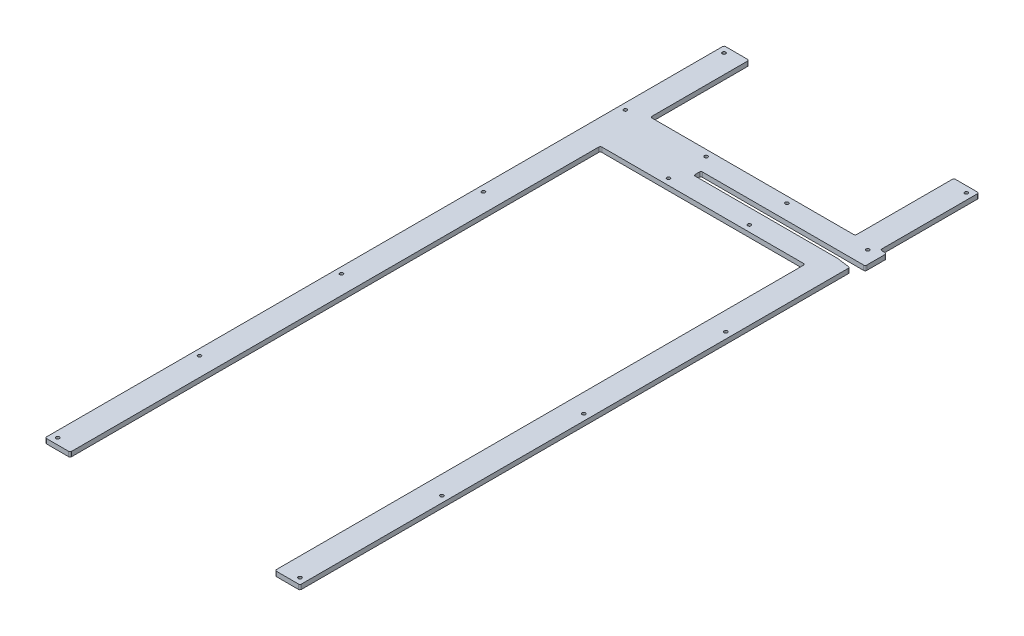
from build123d import *

# Parameters (mm, degrees)
BOSS_EXTRUDE1_DEPTH                                 = 9.525
SKETCH4_W                                           = 50.8
SKETCH4_H                                           = 200
BOSS_EXTRUDE2_DEPTH                                 = 9.525
CSK_FOR_1_4_FLAT_HEAD_MACHINE_SCREW_100_D           = 6.7564
CSK_FOR_1_4_FLAT_HEAD_MACHINE_SCREW_100_CSINK_D     = 17.6447958
CSK_FOR_1_4_FLAT_HEAD_MACHINE_SCREW_100_CSINK_ANGLE = 100
LPATTERN1_COUNT                                     = 2
LPATTERN1_PITCH                                     = 491.2
LPATTERN1_COUNT_DIR2                                = 5
LPATTERN1_PITCH_DIR2                                = 287.65
LPATTERN2_COUNT                                     = 3
LPATTERN2_PITCH                                     = 163.733333333
LPATTERN2_COUNT_DIR2                                = 2
LPATTERN2_PITCH_DIR2                                = 76.2
CSK_FOR_1_4_FLAT_HEAD_MACHINE_SCREW_2_D             = 6.7564
CSK_FOR_1_4_FLAT_HEAD_MACHINE_SCREW_2_CSINK_D       = 17.6447958
CSK_FOR_1_4_FLAT_HEAD_MACHINE_SCREW_2_CSINK_ANGLE   = 100
FILLET1_R                                           = 3.175
FILLET2_R                                           = 3.175


with BuildPart() as part:
    # Sketch1 → Boss-Extrude1 (new body)
    with BuildSketch(Plane(origin=(0, 0, 0), x_dir=(1, 0, 0), z_dir=(0, 1, 0))):
        Polygon((-258.3, 0), (-207.5, 0), (-207.5, 1074.4), (207.5, 1074.4), (207.5, 0), (258.3, 0), (258.3, 1113.914856628), (230.3, 1117.85), (-61.7, 1117.85), (-61.7, 1132.55), (271.3, 1132.55), (271.3, 1176), (-258.3, 1176), align=None)
    extrude(amount=BOSS_EXTRUDE1_DEPTH)

    # Sketch4 → Boss-Extrude2 (add)
    with BuildSketch(Plane.XZ):
        with Locations((-232.9, -1276)):
            Rectangle(SKETCH4_W, SKETCH4_H)
        with Locations((232.9, -1276)):
            Rectangle(SKETCH4_W, SKETCH4_H)
    extrude(amount=-BOSS_EXTRUDE2_DEPTH)

    # CSK for 1_4 Flat Head Machine Screw _100 (through all)
    with Locations(Plane.XZ):
        with Locations((-245.6, -1163.3)):
            csk_for_1_4_flat_head_machine_screw_100 = CounterSinkHole(CSK_FOR_1_4_FLAT_HEAD_MACHINE_SCREW_100_D / 2, CSK_FOR_1_4_FLAT_HEAD_MACHINE_SCREW_100_CSINK_D / 2, counter_sink_angle=CSK_FOR_1_4_FLAT_HEAD_MACHINE_SCREW_100_CSINK_ANGLE)

    # LPattern1: CSK for 1_4 Flat Head Machine Screw _100 2 × 5
    with Locations(*[(i * LPATTERN1_PITCH, 0, j * LPATTERN1_PITCH_DIR2) for i in range(LPATTERN1_COUNT) for j in range(LPATTERN1_COUNT_DIR2) if (i, j) != (0, 0)]):
        add(csk_for_1_4_flat_head_machine_screw_100, mode=Mode.SUBTRACT)

    # LPattern2: CSK for 1_4 Flat Head Machine Screw _100 3 × 2, 1 skipped
    with Locations(*[(i * LPATTERN2_PITCH, 0, j * LPATTERN2_PITCH_DIR2) for i in range(LPATTERN2_COUNT) for j in range(LPATTERN2_COUNT_DIR2) if (i, j) not in ((0, 0), (0, 1))]):
        add(csk_for_1_4_flat_head_machine_screw_100, mode=Mode.SUBTRACT)

    # CSK for 1_4 Flat Head Machine Screw  2 (through all)
    with Locations(Plane.XZ):
        with Locations((-245.6, -1363.3)):
            csk_for_1_4_flat_head_machine_screw_2 = CounterSinkHole(CSK_FOR_1_4_FLAT_HEAD_MACHINE_SCREW_2_D / 2, CSK_FOR_1_4_FLAT_HEAD_MACHINE_SCREW_2_CSINK_D / 2, counter_sink_angle=CSK_FOR_1_4_FLAT_HEAD_MACHINE_SCREW_2_CSINK_ANGLE)

    # Mirror1: CSK for 1_4 Flat Head Machine Screw  2 across plane
    add(csk_for_1_4_flat_head_machine_screw_2.mirror(Plane(origin=(0, 0, 0), x_dir=(0, 0, 1), z_dir=(1, 0, 0))), mode=Mode.SUBTRACT)

    # Fillet1
    fillet1_edges = [part.edges().sort_by_distance(p)[0] for p in [
        (258.3, 4.7625, 0),
        (207.5, 4.7625, 0),
        (-207.5, 4.7625, 0),
        (-258.3, 4.7625, 0),
        (207.5, 4.7625, -1074.4),
        (-207.5, 4.7625, -1074.4),
        (258.3, 4.7625, -1113.914856628),
        (271.3, 4.7625, -1132.55),
        (271.3, 4.7625, -1176),
        (-61.7, 4.7625, -1117.85),
        (-61.7, 4.7625, -1132.55),
    ]]
    fillet(fillet1_edges, radius=FILLET1_R)

    # Fillet2
    fillet2_edges = [part.edges().sort_by_distance(p)[0] for p in [
        (207.5, 4.7625, -1376),
        (258.3, 4.7625, -1376),
        (-258.3, 4.7625, -1376),
        (-207.5, 4.7625, -1376),
        (-207.5, 4.7625, -1176),
        (207.5, 4.7625, -1176),
        (258.3, 4.7625, -1176),
    ]]
    fillet(fillet2_edges, radius=FILLET2_R)


solid = part.part
